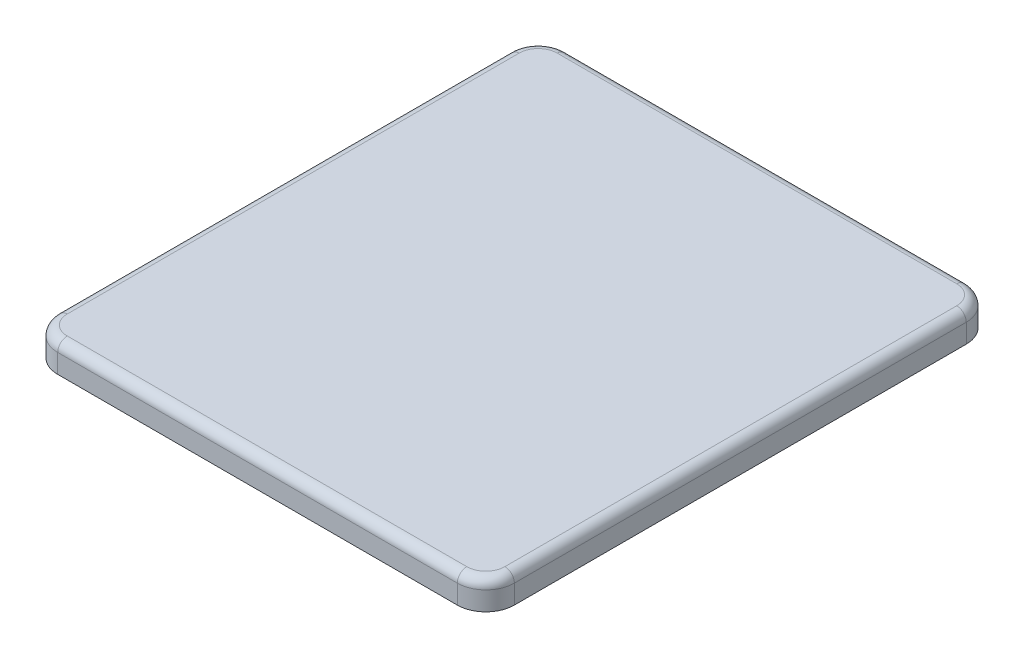
from build123d import *

# Parameters (mm, degrees)
SKETCH1_W           = 48
SKETCH1_H           = 53.5
BOSS_EXTRUDE1_DEPTH = 3
FILLET1_R           = 3
FILLET2_R           = 1


with BuildPart() as part:
    # Sketch1 → Boss-Extrude1 (new body)
    with BuildSketch(Plane(origin=(0, 0, 0), x_dir=(1, 0, 0), z_dir=(0, 1, 0))):
        Rectangle(SKETCH1_W, SKETCH1_H)
    extrude(amount=BOSS_EXTRUDE1_DEPTH)

    # Fillet1
    fillet1_edges = [part.edges().sort_by_distance(p)[0] for p in [
        (24, 1.5, 26.75),
        (-24, 1.5, 26.75),
        (-24, 1.5, -26.75),
        (24, 1.5, -26.75),
    ]]
    fillet(fillet1_edges, radius=FILLET1_R)

    # Fillet2
    fillet2_edges = [part.edges().sort_by_distance(p)[0] for p in [
        (0, 3, 26.75),
        (-24, 3, 0),
        (24, 3, 0),
        (0, 3, -26.75),
        (23.121320344, 3, 25.871320344),
        (23.121320344, 3, -25.871320344),
        (-23.121320344, 3, -25.871320344),
        (-23.121320344, 3, 25.871320344),
    ]]
    fillet(fillet2_edges, radius=FILLET2_R)


solid = part.part
